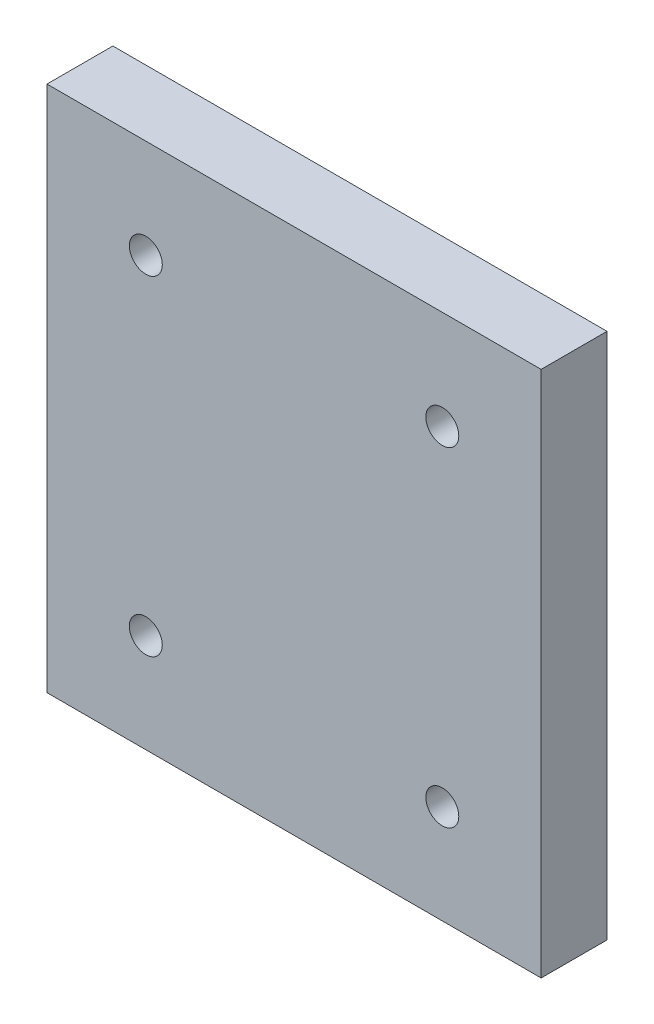
from build123d import *

# Parameters (mm, degrees)
SKETCH1_W           = 75
SKETCH1_H           = 80
SKETCH1_W_2         = 55
SKETCH1_H_2         = 60
SKETCH1_R           = 2.5
BOSS_EXTRUDE1_DEPTH = 10


with BuildPart() as part:
    # Sketch1 → Boss-Extrude1 (new body)
    with BuildSketch(Plane.XY):
        with Locations((27.5, 30)):
            Rectangle(SKETCH1_W, SKETCH1_H)
        with Locations((27.5, 30)):
            Rectangle(SKETCH1_W_2, SKETCH1_H_2, mode=Mode.SUBTRACT)
        with Locations((27.5, 30)):
            Rectangle(SKETCH1_W_2, SKETCH1_H_2)
        with Locations((50, 5)):
            Circle(SKETCH1_R, mode=Mode.SUBTRACT)
        with Locations((5, 5)):
            Circle(SKETCH1_R, mode=Mode.SUBTRACT)
        with Locations((5, 55)):
            Circle(SKETCH1_R, mode=Mode.SUBTRACT)
        with Locations((50, 55)):
            Circle(SKETCH1_R, mode=Mode.SUBTRACT)
    extrude(amount=BOSS_EXTRUDE1_DEPTH)


solid = part.part
